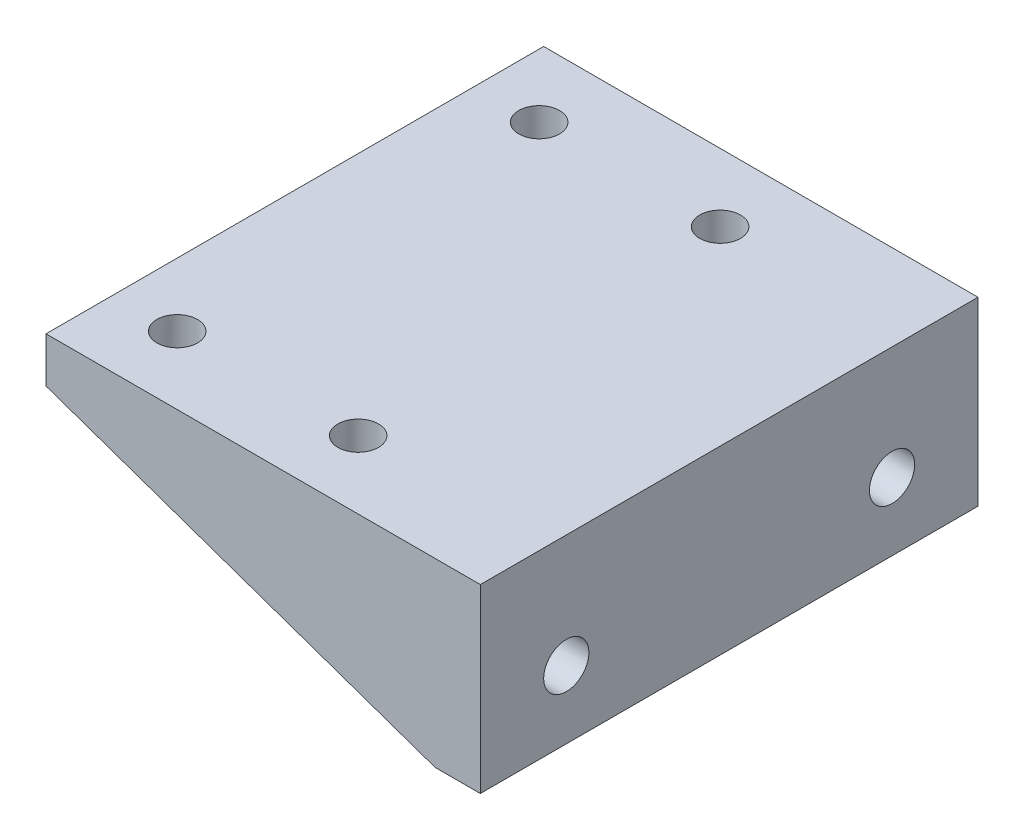
from build123d import *

# Parameters (mm, degrees)
SKETCH1_W           = 30
SKETCH1_H           = 55
BOSS_EXTRUDE1_DEPTH = 5
SKETCH4_W           = 55
SKETCH4_H           = 5
BOSS_EXTRUDE2_DEPTH = 18
SKETCH5_W           = 55
SKETCH5_H           = 20
BOSS_EXTRUDE3_DEPTH = 5
SKETCH6_R           = 2.5
CUT_EXTRUDE3_DEPTH  = 5
BOSS_EXTRUDE4_DEPTH = 3
SKETCH8_R           = 2.25
CUT_EXTRUDE4_DEPTH  = 10


with BuildPart() as part:
    # Sketch1 → Boss-Extrude1 (new body)
    with BuildSketch(Plane(origin=(0, 0, 0), x_dir=(1, 0, 0), z_dir=(0, 1, 0))):
        Rectangle(SKETCH1_W, SKETCH1_H)
    extrude(amount=BOSS_EXTRUDE1_DEPTH)

    # Sketch4 → Boss-Extrude2 (add)
    with BuildSketch(Plane(origin=(15, 0, 0), x_dir=(0, 0, -1), z_dir=(1, 0, 0))):
        with Locations((0, 2.5)):
            Rectangle(SKETCH4_W, SKETCH4_H)
    extrude(amount=BOSS_EXTRUDE2_DEPTH)

    # Sketch5 → Boss-Extrude3 (add)
    with BuildSketch(Plane(origin=(33, 0, 0), x_dir=(0, 0, -1), z_dir=(1, 0, 0))):
        with Locations((0, -5)):
            Rectangle(SKETCH5_W, SKETCH5_H)
    extrude(amount=-BOSS_EXTRUDE3_DEPTH)

    # Sketch6 → Cut-Extrude3 (cut)
    with BuildSketch(Plane(origin=(33, 0, 0), x_dir=(0, 0, -1), z_dir=(1, 0, 0))):
        with Locations((18, -7.5)):
            Circle(SKETCH6_R)
        with Locations((-18, -7.5)):
            Circle(SKETCH6_R)
    extrude(amount=-CUT_EXTRUDE3_DEPTH, mode=Mode.SUBTRACT)

    # Sketch7 → Boss-Extrude4 (add)
    with BuildSketch(Plane.XY.offset(27.5)):
        Polygon((28, -15), (-15, 0), (28, 0), align=None)
    boss_extrude4 = extrude(amount=-BOSS_EXTRUDE4_DEPTH)

    # Mirror1: Boss-Extrude4 across plane
    add(boss_extrude4.mirror(Plane.XY))

    # Sketch8 → Cut-Extrude4 (cut)
    with BuildSketch(Plane.XZ):
        with Locations((-8, 20)):
            Circle(SKETCH8_R)
        with Locations((-8, -20)):
            Circle(SKETCH8_R)
        with Locations((12, 20)):
            Circle(SKETCH8_R)
        with Locations((12, -20)):
            Circle(SKETCH8_R)
    extrude(amount=-CUT_EXTRUDE4_DEPTH, mode=Mode.SUBTRACT)


solid = part.part
